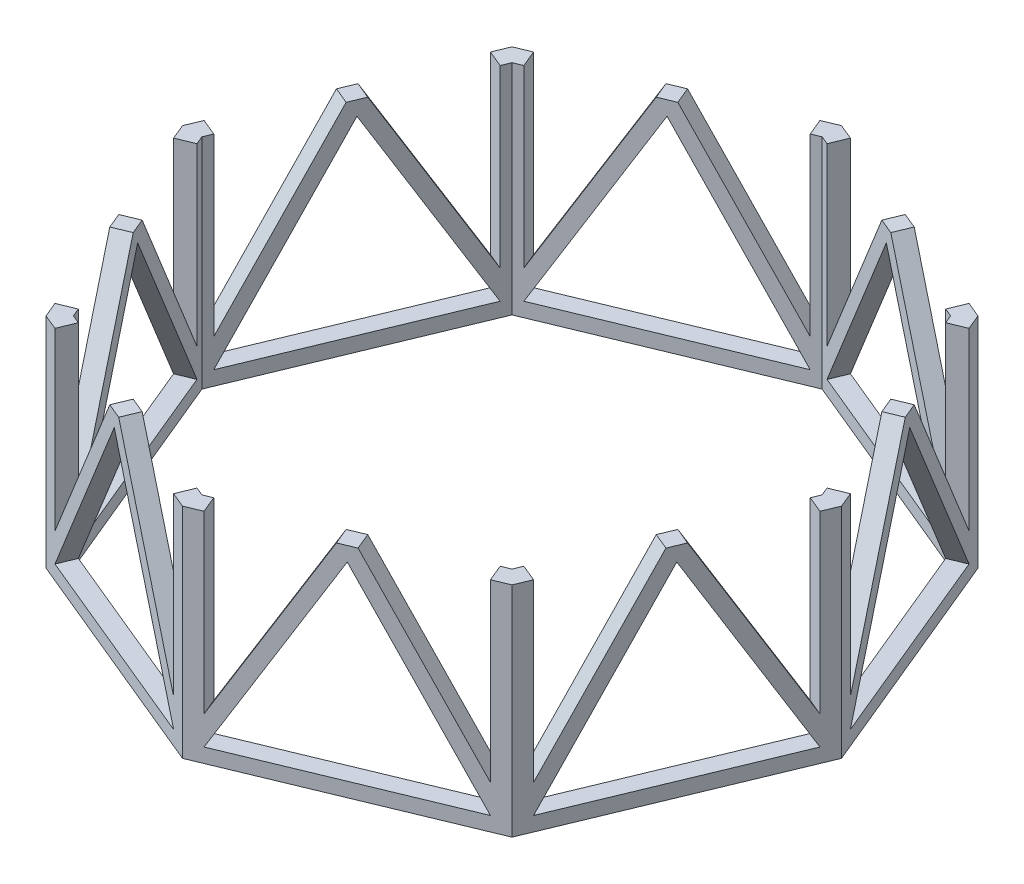
from build123d import *

# Parameters (mm, degrees)
BOSS_EXTRUDE1_DEPTH = 100
BOSS_EXTRUDE2_DEPTH = 125
CIRPATTERN1_COUNT   = 8


with BuildPart() as part:
    # Sketch1 → Boss-Extrude1 (new body)
    with BuildSketch(Plane(origin=(0, 0, 0), x_dir=(1, 0, 0), z_dir=(0, 1, 0))):
        Polygon((2300.083425621, 0), (1626.404587552, 1626.404587552), (0, 2300.083425621), (-1626.404587552, 1626.404587552), (-2300.083425621, 0), (-1626.404587552, -1626.404587552), (0, -2300.083425621), (1626.404587552, -1626.404587552), align=None)
        Polygon((2164.784400585, 0), (1530.73372946, 1530.73372946), (0, 2164.784400585), (-1530.73372946, 1530.73372946), (-2164.784400585, 0), (-1530.73372946, -1530.73372946), (0, -2164.784400585), (1530.73372946, -1530.73372946), align=None, mode=Mode.SUBTRACT)
    extrude(amount=BOSS_EXTRUDE1_DEPTH)

    # Sketch2 → Boss-Extrude2 (add)
    with BuildSketch(Plane(origin=(813.202293776, 0, 1963.244006586), x_dir=(0.9238795325112844, 0, -0.3826834323650955), z_dir=(0.3826834323650955, 0, 0.9238795325112844))):
        Polygon((-57.735026919, 1525.068742177), (-765.028794991, 300), (-765.028794991, 1525.068742177), (-880.498848829, 1525.068742177), (-880.498848829, 100), (-765.028794991, 100), (0, 1425.068742177), (765.028794991, 100), (880.498848829, 100), (880.498848829, 1525.068742177), (765.028794991, 1525.068742177), (765.028794991, 300), (57.735026919, 1525.068742177), align=None)
    boss_extrude2 = extrude(amount=-BOSS_EXTRUDE2_DEPTH)

    # CirPattern1: Boss-Extrude2 ×8 about axis
    cirpattern1_axis = Axis((0, 1601.322179286, 0), (0, -1, 0))
    for i in range(1, CIRPATTERN1_COUNT):
        add(boss_extrude2.rotate(cirpattern1_axis, i * 360 / CIRPATTERN1_COUNT))


solid = part.part
